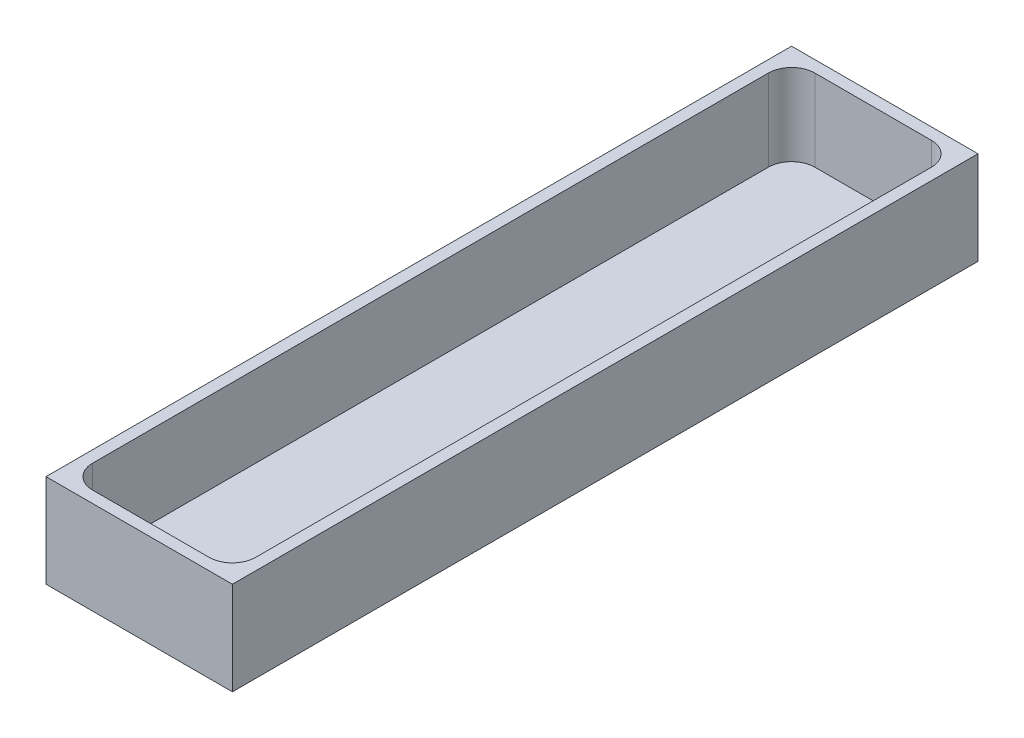
from build123d import *

# Parameters (mm, degrees)
SKETCH1_W           = 50.8
SKETCH1_H           = 203.2
BOSS_EXTRUDE1_DEPTH = 25.4
SHELL1_T            = -3.175
FILLET1_R           = 6.35


with BuildPart() as part:
    # Sketch1 → Boss-Extrude1 (new body)
    with BuildSketch(Plane(origin=(0, 0, 0), x_dir=(1, 0, 0), z_dir=(0, 1, 0))):
        with Locations((25.4, 101.6)):
            Rectangle(SKETCH1_W, SKETCH1_H)
    extrude(amount=BOSS_EXTRUDE1_DEPTH)

    # Shell1
    shell1_openings = [part.faces().sort_by_distance(p)[0] for p in [
        (25.4, 25.4, -101.6),
    ]]
    offset(amount=SHELL1_T, openings=shell1_openings, kind=Kind.INTERSECTION)

    # Fillet1
    fillet1_edges = [part.edges().sort_by_distance(p)[0] for p in [
        (3.175, 14.2875, -200.025),
        (3.175, 14.2875, -3.175),
        (47.625, 14.2875, -3.175),
        (47.625, 14.2875, -200.025),
    ]]
    fillet(fillet1_edges, radius=FILLET1_R)


solid = part.part
